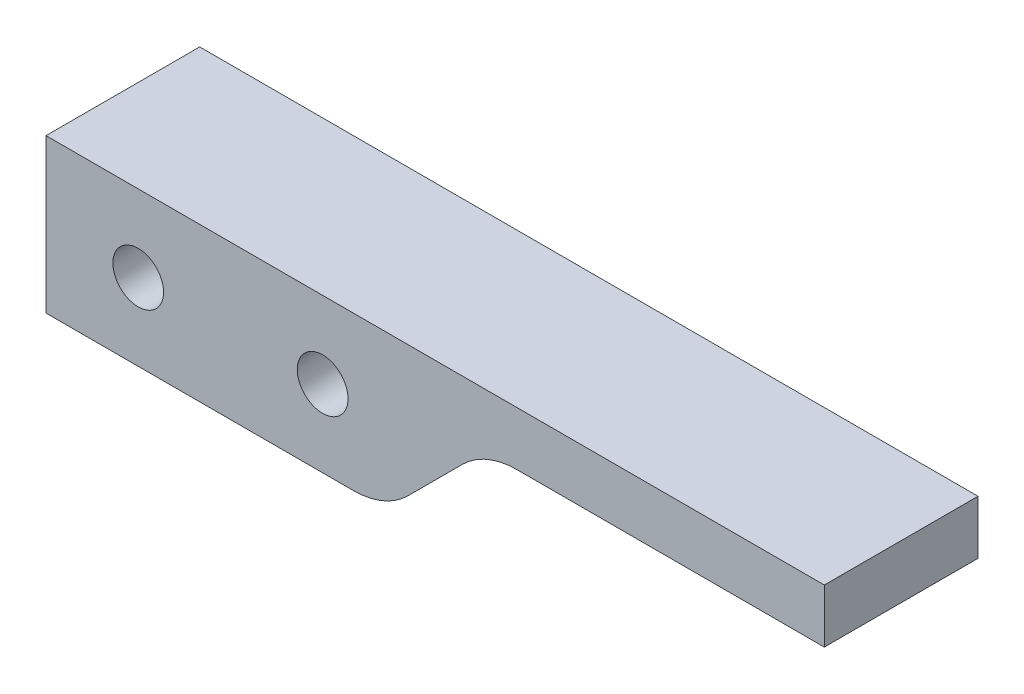
from build123d import *

# Parameters (mm, degrees)
EXTRUDE_1_DEPTH    = 10
HOLE_WIZARD_M4_1_D = 3.3


with BuildPart() as part:
    # 草图5 → 凸台-拉伸1 (new body)
    with BuildSketch(Plane.XY):
        with BuildLine():
            Line((7834.715889536, 44.670845652), (7854.715889536, 44.670845652))
            ThreePointArc((7854.715889536, 44.670845652), (7856.629306698, 45.05144799), (7858.251423442, 46.135311746))
            Line((7858.251423442, 46.135311746), (7861.822491254, 49.706379558))
            ThreePointArc((7861.822491254, 49.706379558), (7863.444607998, 50.790243315), (7865.358025159, 51.170845652))
            Line((7865.358025159, 51.170845652), (7885.358025159, 51.170845652))
            Line((7885.358025159, 51.170845652), (7885.358025159, 54.670845652))
            Line((7885.358025159, 54.670845652), (7834.715889536, 54.670845652))
            Line((7834.715889536, 54.670845652), (7834.715889536, 44.670845652))
        make_face()
    extrude(amount=EXTRUDE_1_DEPTH)

    # M4 螺纹孔1 (through all)
    with Locations(Plane.XY.offset(10)):
        with Locations((7840.715889536, 49.670845652), (7852.715889536, 49.670845652)):
            Hole(HOLE_WIZARD_M4_1_D / 2)


solid = part.part
